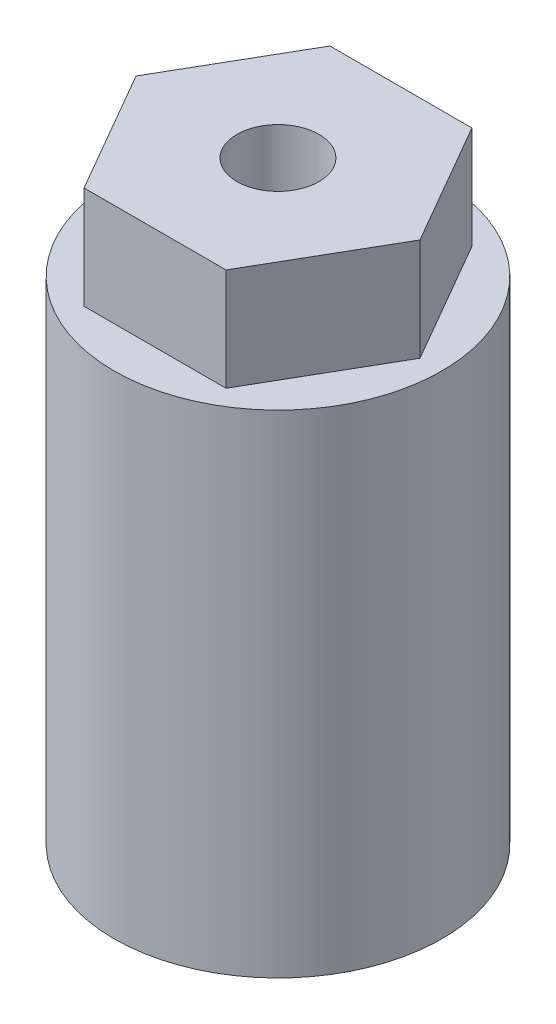
from build123d import *

# Parameters (mm, degrees)
SKETCH1_W                 = 4
SKETCH1_H                 = 12
SKETCH1_W_2               = 8
BOSS_EXTRUDE1_DEPTH       = 5
F_4_0MM_DOWEL_HOLE1_D     = 4
F_4_0MM_DOWEL_HOLE1_DEPTH = 10
F_4_0MM_DOWEL_HOLE1_TIP   = 1.201721238
CUT_EXTRUDE1_START        = -12
SKETCH5_W                 = 3
SKETCH5_H                 = 3
CUT_EXTRUDE1_DEPTH        = 12


with BuildPart() as part:
    # Sketch1 → Revolve1 (revolve)
    with BuildSketch(Plane.XY):
        with Locations((6, 6)):
            Rectangle(SKETCH1_W, SKETCH1_H)
        with Locations((4, 18)):
            Rectangle(SKETCH1_W_2, SKETCH1_H)
    revolve(axis=Axis((0, 0, 0), (0, 1, 0)))

    # Sketch2 → Boss-Extrude1 (add)
    with BuildSketch(Plane(origin=(0, 24, 0), x_dir=(1, 0, 0), z_dir=(0, 1, 0))):
        Polygon((6.92820323, 0), (3.464101615, 6), (-3.464101615, 6), (-6.92820323, 0), (-3.464101615, -6), (3.464101615, -6), align=None)
    extrude(amount=BOSS_EXTRUDE1_DEPTH)

    # Ø4.0mm Dowel Hole1
    with Locations(Plane(origin=(0, 29, 0), x_dir=(1, 0, 0), z_dir=(0, 1, 0))):
        with Locations((0, 0)):
            Hole(F_4_0MM_DOWEL_HOLE1_D / 2, depth=F_4_0MM_DOWEL_HOLE1_DEPTH)
            with Locations((0, 0, -(F_4_0MM_DOWEL_HOLE1_DEPTH + F_4_0MM_DOWEL_HOLE1_TIP / 2))):  # 118° drill point
                Cone(0, F_4_0MM_DOWEL_HOLE1_D / 2, F_4_0MM_DOWEL_HOLE1_TIP, mode=Mode.SUBTRACT)

    # Sketch5 → Cut-Extrude1 (cut)
    with BuildSketch(Plane.XZ.offset(CUT_EXTRUDE1_START)):
        with Locations((4, 0)):
            Rectangle(SKETCH5_W, SKETCH5_H)
    extrude(amount=CUT_EXTRUDE1_DEPTH, mode=Mode.SUBTRACT)


solid = part.part
